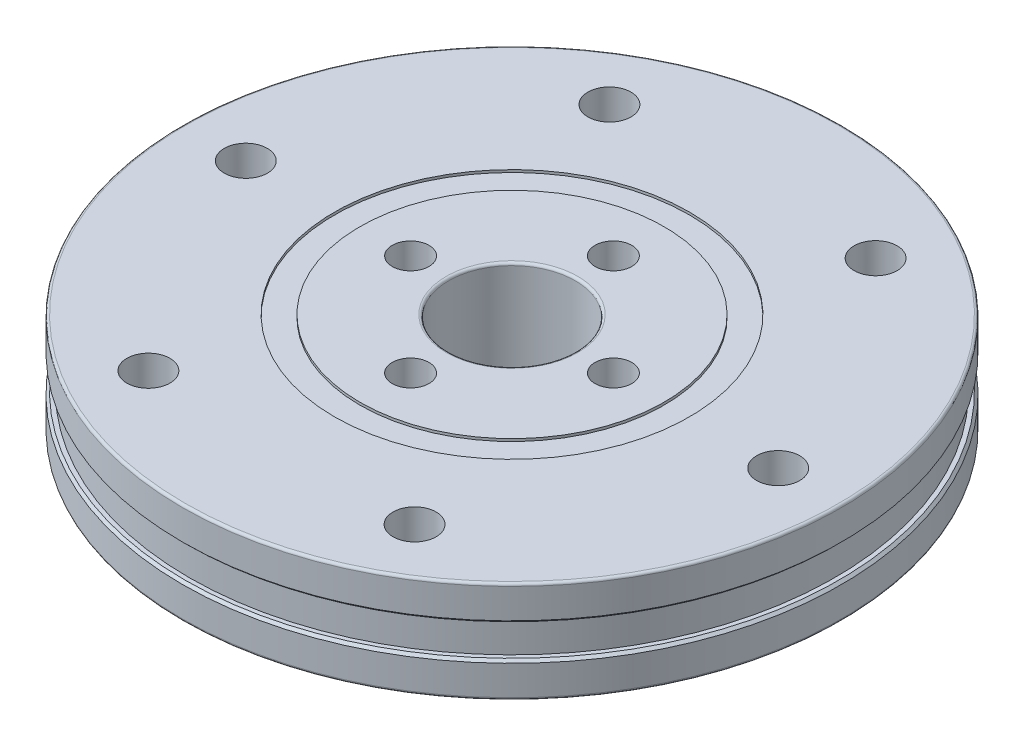
from build123d import *

# Parameters (mm, degrees)
SKETCH_1_R          = 26
SKETCH_1_R_2        = 5
SKETCH_1_R_3        = 1.7
SKETCH_1_R_4        = 1.45
EXTRUDE_1_DEPTH     = 4
SKETCH_2_R          = 14
SKETCH_2_R_2        = 12
CUT_EXTRUDE_1_DEPTH = 0.2
SKETCH_3_R          = 14
SKETCH_3_R_2        = 12
CUT_EXTRUDE_2_DEPTH = 0.2
SKETCH_5_R          = 27.923918385
SKETCH_5_R_2        = 25.46843451
CUT_EXTRUDE_3_DEPTH = 1.25
CHAMFER_1_SIZE      = 0.2
FILLET_1_R          = 0.2
SKETCH_6_R          = 3.25
CUT_EXTRUDE_4_DEPTH = 3.3


with BuildPart() as part:
    # 草图1 → 凸台-拉伸1 (new body, symmetric)
    with BuildSketch(Plane(origin=(0, 0, 0), x_dir=(1, 0, 0), z_dir=(0, 1, 0))):
        Circle(SKETCH_1_R)
        Circle(SKETCH_1_R_2, mode=Mode.SUBTRACT)
        with Locations((-10.5, 18.186533479)):
            Circle(SKETCH_1_R_3, mode=Mode.SUBTRACT)
        with Locations((10.5, 18.186533479)):
            Circle(SKETCH_1_R_3, mode=Mode.SUBTRACT)
        with Locations((21, 0)):
            Circle(SKETCH_1_R_3, mode=Mode.SUBTRACT)
        with Locations((10.5, -18.186533479)):
            Circle(SKETCH_1_R_3, mode=Mode.SUBTRACT)
        with Locations((-10.5, -18.186533479)):
            Circle(SKETCH_1_R_3, mode=Mode.SUBTRACT)
        with Locations((-21, 0)):
            Circle(SKETCH_1_R_3, mode=Mode.SUBTRACT)
        with Locations((0, 8)):
            Circle(SKETCH_1_R_4, mode=Mode.SUBTRACT)
        with Locations((8, 0)):
            Circle(SKETCH_1_R_4, mode=Mode.SUBTRACT)
        with Locations((0, -8)):
            Circle(SKETCH_1_R_4, mode=Mode.SUBTRACT)
        with Locations((-8, 0)):
            Circle(SKETCH_1_R_4, mode=Mode.SUBTRACT)
    extrude(amount=EXTRUDE_1_DEPTH, both=True)

    # 草图2 → 切除-拉伸1 (cut)
    with BuildSketch(Plane(origin=(0, 4, 0), x_dir=(1, 0, 0), z_dir=(0, 1, 0))):
        Circle(SKETCH_2_R)
        Circle(SKETCH_2_R_2, mode=Mode.SUBTRACT)
    extrude(amount=-CUT_EXTRUDE_1_DEPTH, mode=Mode.SUBTRACT)

    # 草图3 → 切除-拉伸2 (cut)
    with BuildSketch(Plane.XZ.offset(4)):
        Circle(SKETCH_3_R)
        Circle(SKETCH_3_R_2, mode=Mode.SUBTRACT)
    extrude(amount=-CUT_EXTRUDE_2_DEPTH, mode=Mode.SUBTRACT)

    # 草图5 → 切除-拉伸3 (cut, symmetric)
    with BuildSketch(Plane(origin=(0, 0, 0), x_dir=(1, 0, 0), z_dir=(0, 1, 0))):
        Circle(SKETCH_5_R)
        Circle(SKETCH_5_R_2, mode=Mode.SUBTRACT)
    extrude(amount=CUT_EXTRUDE_3_DEPTH, both=True, mode=Mode.SUBTRACT)

    # 倒角1
    chamfer_1_edges = [part.edges().sort_by_distance(p)[0] for p in [
        (-26, 1.25, 0),
        (-26, -1.25, 0),
    ]]
    chamfer(chamfer_1_edges, length=CHAMFER_1_SIZE)

    # 圆角1
    fillet_1_edges = [part.edges().sort_by_distance(p)[0] for p in [
        (-26, -4, 0),
        (-26, 4, 0),
        (-5, -4, 0),
        (-5, 4, 0),
    ]]
    fillet(fillet_1_edges, radius=FILLET_1_R)

    # 草图6 → 切除-拉伸4 (cut)
    with BuildSketch(Plane.XZ.offset(4)):
        with Locations((-21, 0)):
            Circle(SKETCH_6_R)
        with Locations((-10.5, -18.186533479)):
            Circle(SKETCH_6_R)
        with Locations((10.5, -18.186533479)):
            Circle(SKETCH_6_R)
        with Locations((21, 0)):
            Circle(SKETCH_6_R)
        with Locations((10.5, 18.186533479)):
            Circle(SKETCH_6_R)
        with Locations((-10.5, 18.186533479)):
            Circle(SKETCH_6_R)
    extrude(amount=-CUT_EXTRUDE_4_DEPTH, mode=Mode.SUBTRACT)


solid = part.part
